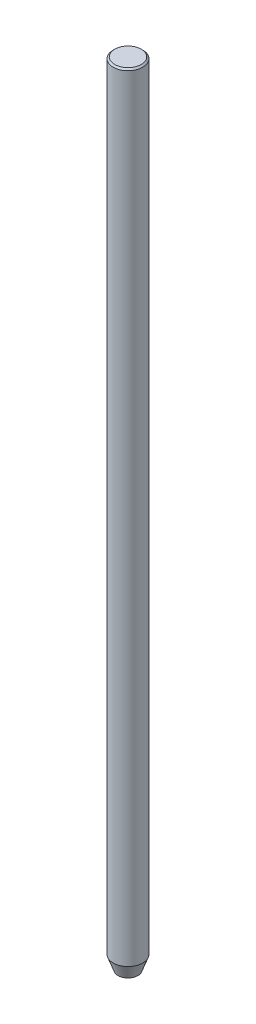
from build123d import *

# Parameters (mm, degrees)
SKETCH1_R           = 2.38125
BOSS_EXTRUDE1_DEPTH = 127
CHAMFER1_SIZE       = 0.25


with BuildPart() as part:
    # Sketch1 → Boss-Extrude1 (new body)
    with BuildSketch(Plane(origin=(0, 0, 0), x_dir=(1, 0, 0), z_dir=(0, 1, 0))):
        Circle(SKETCH1_R)
    extrude(amount=BOSS_EXTRUDE1_DEPTH)

    # Chamfer1
    chamfer1_edges = [part.edges().sort_by_distance(p)[0] for p in [
        (-2.38125, 0, 0),
        (-2.38125, 127, 0),
    ]]
    chamfer(chamfer1_edges, length=CHAMFER1_SIZE)

    # Sketch2 → Cut-Revolve1 (revolve, cut)
    with BuildSketch(Plane(origin=(0, 0, 0), x_dir=(0, 0, -1), z_dir=(1, 0, 0))):
        Polygon((1.6, 0), (2.6, 2.747477419), (2.6, 0), align=None)
    revolve(axis=Axis((0, 0, 0), (0, 1, 0)), mode=Mode.SUBTRACT)


solid = part.part
